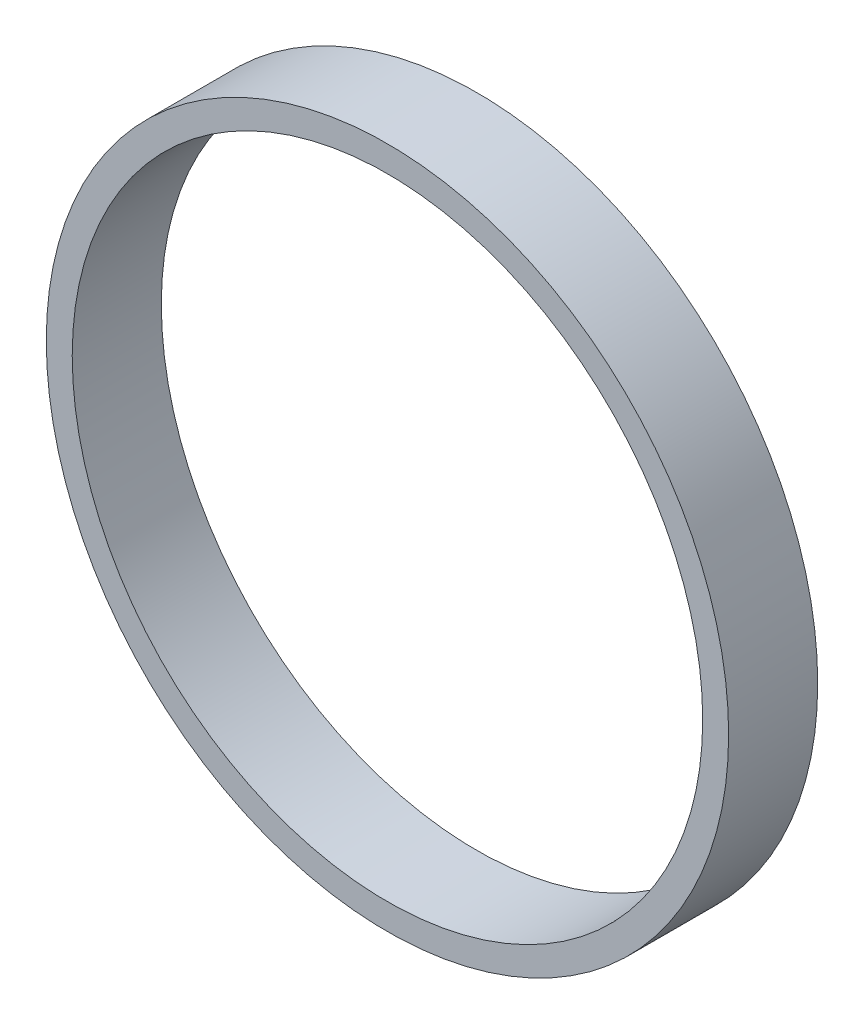
from build123d import *

# Parameters (mm, degrees)
SKETCH1_R           = 78.9
SKETCH1_R_2         = 72.9
BOSS_EXTRUDE1_DEPTH = 10.3


with BuildPart() as part:
    # Sketch1 → Boss-Extrude1 (new, symmetric)
    with BuildSketch(Plane.XY):
        Circle(SKETCH1_R)
        Circle(SKETCH1_R_2, mode=Mode.SUBTRACT)
    extrude(amount=BOSS_EXTRUDE1_DEPTH, both=True)


solid = part.part
